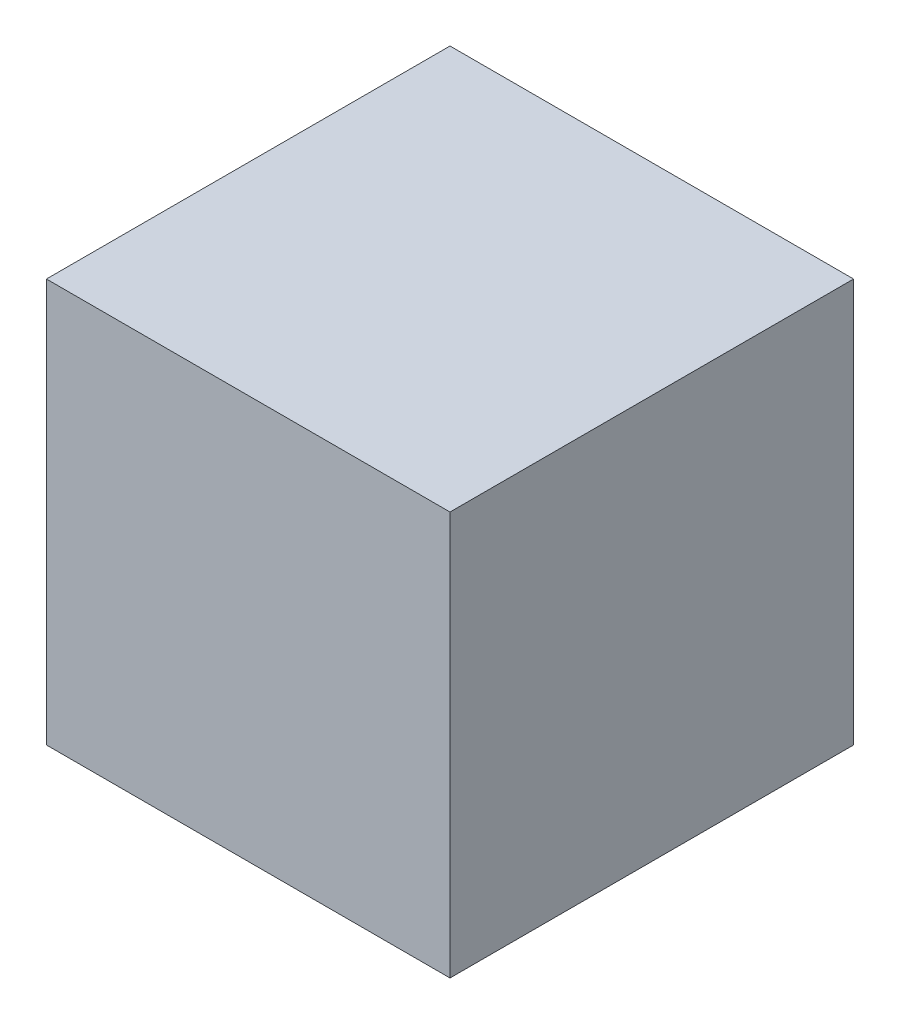
from build123d import *

# Parameters (mm, degrees)
SKETCH_1_W      = 39
SKETCH_1_H      = 39
EXTRUDE_1_DEPTH = 39


with BuildPart() as part:
    # 草圖1 → 填料-伸長1 (new body)
    with BuildSketch(Plane.XY):
        Rectangle(SKETCH_1_W, SKETCH_1_H)
    extrude(amount=EXTRUDE_1_DEPTH)


solid = part.part
